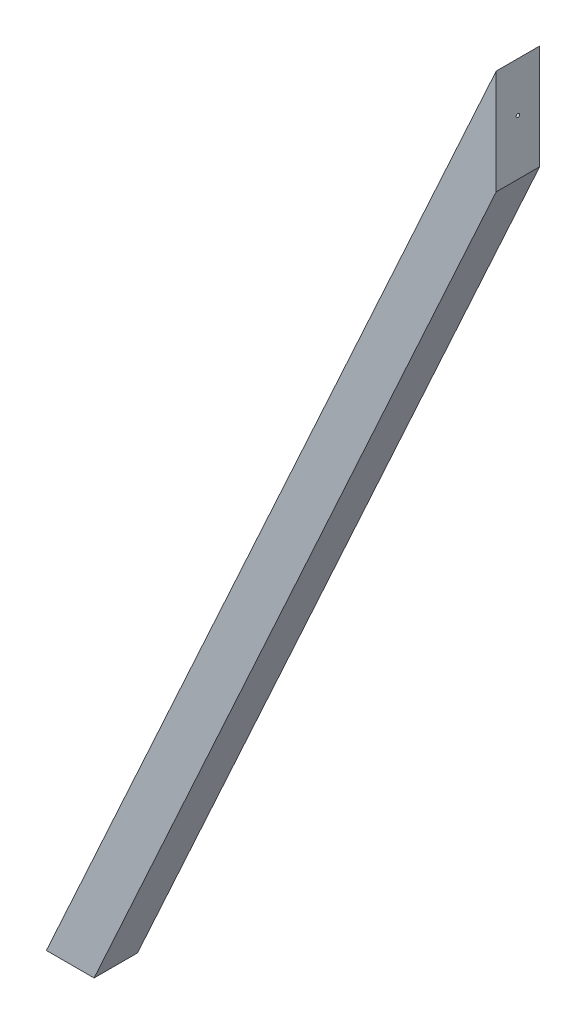
from build123d import *

# Parameters (mm, degrees)
BOSS_EXTRU_1_DEPTH      = 44
ENL_V_MAT_EXTRU_1_REACH = 458
ESQUISSE2_R             = 1.75


with BuildPart() as part:
    # Esquisse1 → Boss.-Extru.1 (new body)
    with BuildSketch(Plane.XY):
        Polygon((-44, 1000), (-500, 0), (-451.641297619, 0), (-44, 893.950214076), align=None)
    extrude(amount=BOSS_EXTRU_1_DEPTH)

    # Enlèv. mat.-Extru.1: up to this face of the body (flat: up to its plane)
    enl_v_mat_extru_1_end = Plane(part.part.faces().sort_by_distance((-272, 500, 22))[0])
    # Esquisse2 → Enlèv. mat.-Extru.1 (cut, up to the picked face)
    with BuildSketch(Plane(origin=(-44, 0, 0), x_dir=(0, 0, -1), z_dir=(1, 0, 0)), mode=Mode.PRIVATE) as enl_v_mat_extru_1_sk1:
        with Locations((-22, 950)):
            Circle(ESQUISSE2_R)
    enl_v_mat_extru_1_tool1 = split(extrude(enl_v_mat_extru_1_sk1.sketch, amount=-ENL_V_MAT_EXTRU_1_REACH, mode=Mode.PRIVATE), bisect_by=enl_v_mat_extru_1_end, keep=Keep.BOTH, mode=Mode.PRIVATE)
    add(enl_v_mat_extru_1_tool1.solids().sort_by_distance((-44, 950, 22))[0], mode=Mode.SUBTRACT)


solid = part.part
